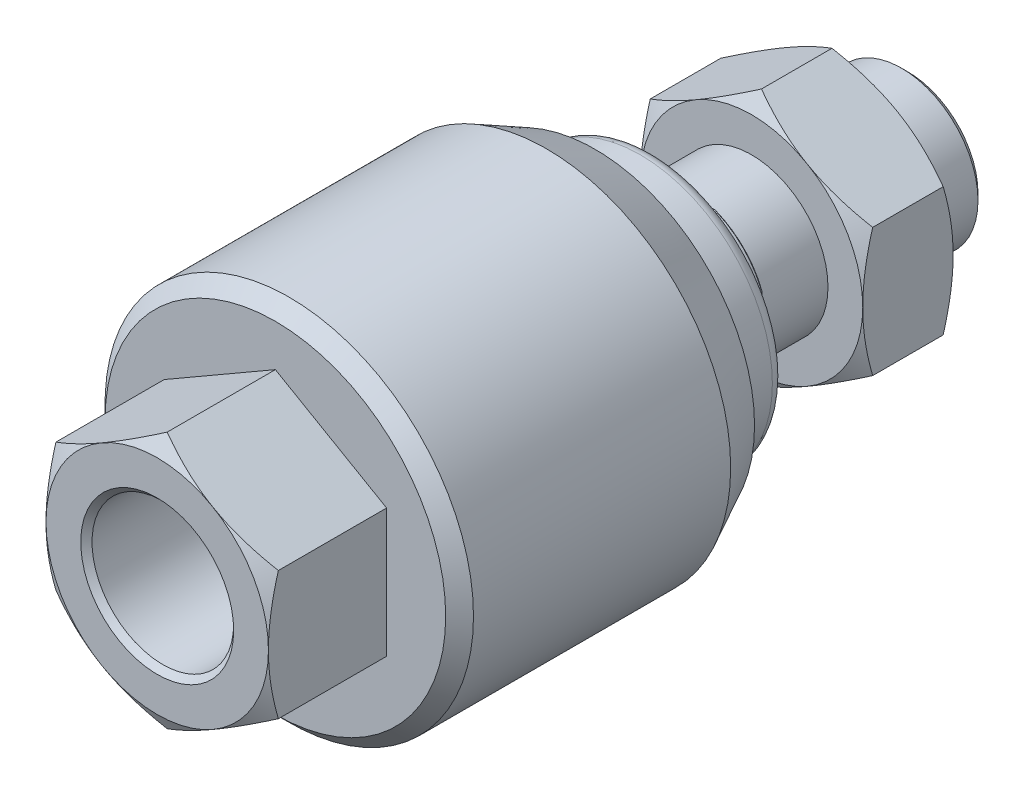
from build123d import *

# Parameters (mm, degrees)
SKETCH_2_R          = 33
SKETCH_2_W          = 44
SKETCH_2_H          = 22
CUT_EXTRUDE_1_DEPTH = 6.5
SKETCH_3_R          = 33
SKETCH_3_W          = 22
SKETCH_3_H          = 44
CUT_EXTRUDE_2_DEPTH = 6.5
SKETCH_5_R          = 32
CUT_EXTRUDE_3_DEPTH = 17
SKETCH_7_R          = 32
CUT_EXTRUDE_4_DEPTH = 13


with BuildPart() as part:
    # 草图1 → 旋转1 (revolve)
    with BuildSketch(Plane(origin=(0, 0, 0), x_dir=(0, 0, -1), z_dir=(1, 0, 0))):
        Polygon((-83, 0), (-83, 10.188), (-107.188, 10.188), (-108, 11), (-108, 16), (-106.57093764, 18.475208614), (-91.6, 18.475208614), (-91, 19.075208614), (-91, 24.5), (-89, 26.5), (-52, 26.5), (-45, 22.933321854), (-45, 10.5), (-38.5, 10.5), (-38.5, 11.8), (-38.3, 12), (-32.2, 12), (-32, 11.8), (-32, 11), (-0.92, 11), (0, 10.08), (0, 0), align=None)
    revolve(axis=Axis((0, 0, 0), (0, 0, 1)))

    # 草图2 → 切除-拉伸1 (cut)
    with BuildSketch(Plane(origin=(0, 0, 32), x_dir=(-1, 0, 0), z_dir=(0, 0, -1))):
        Circle(SKETCH_2_R)
        Rectangle(SKETCH_2_W, SKETCH_2_H, mode=Mode.SUBTRACT)
    extrude(amount=-CUT_EXTRUDE_1_DEPTH, mode=Mode.SUBTRACT)

    # 草图3 → 切除-拉伸2 (cut)
    with BuildSketch(Plane(origin=(0, 0, 32), x_dir=(-1, 0, 0), z_dir=(0, 0, -1))):
        Circle(SKETCH_3_R)
        Rectangle(SKETCH_3_W, SKETCH_3_H, mode=Mode.SUBTRACT)
    extrude(amount=-CUT_EXTRUDE_2_DEPTH, mode=Mode.SUBTRACT)

    # 草图4 → 旋转2 (revolve)
    with BuildSketch(Plane(origin=(0, 0, 0), x_dir=(0, 0, -1), z_dir=(1, 0, 0))):
        with BuildLine():
            Line((-45, 19), (-45, 10.5))
            Line((-45, 10.5), (-38.5, 10.5))
            Line((-38.5, 10.5), (-38.5, 11.8))
            Line((-38.5, 11.8), (-36.726286637, 16.418867925))
            ThreePointArc((-36.726286637, 16.418867925), (-36.934089571, 18.176069017), (-38.5, 19))
            Line((-38.5, 19), (-45, 19))
        make_face()
    revolve(axis=Axis((0, 0, -50), (0, 0, 1)))

    # 草图5 → 切除-拉伸3 (cut)
    with BuildSketch(Plane.XY.offset(108)):
        Circle(SKETCH_5_R)
        Polygon((0, -18.475208614), (16, -9.237604307), (16, 9.237604307), (0, 18.475208614), (-16, 9.237604307), (-16, -9.237604307), align=None, mode=Mode.SUBTRACT)
    extrude(amount=-CUT_EXTRUDE_3_DEPTH, mode=Mode.SUBTRACT)

    # 草图6 → 旋转3 (revolve)
    with BuildSketch(Plane(origin=(0, 0, 0), x_dir=(0, 0, -1), z_dir=(1, 0, 0))):
        Polygon((-22.5, 16), (-22.5, 11), (-21.688, 10.188), (-10.312, 10.188), (-9.5, 11), (-9.5, 16), (-10.92906236, 18.475208614), (-21.07093764, 18.475208614), align=None)
    revolve(axis=Axis((0, 0, 9.5), (0, 0, 1)))

    # 草图7 → 切除-拉伸4 (cut)
    with BuildSketch(Plane(origin=(0, 0, 9.5), x_dir=(-1, 0, 0), z_dir=(0, 0, -1))):
        Circle(SKETCH_7_R)
        Polygon((0, -18.475208614), (16, -9.237604307), (16, 9.237604307), (0, 18.475208614), (-16, 9.237604307), (-16, -9.237604307), align=None, mode=Mode.SUBTRACT)
    extrude(amount=-CUT_EXTRUDE_4_DEPTH, mode=Mode.SUBTRACT)


solid = part.part
